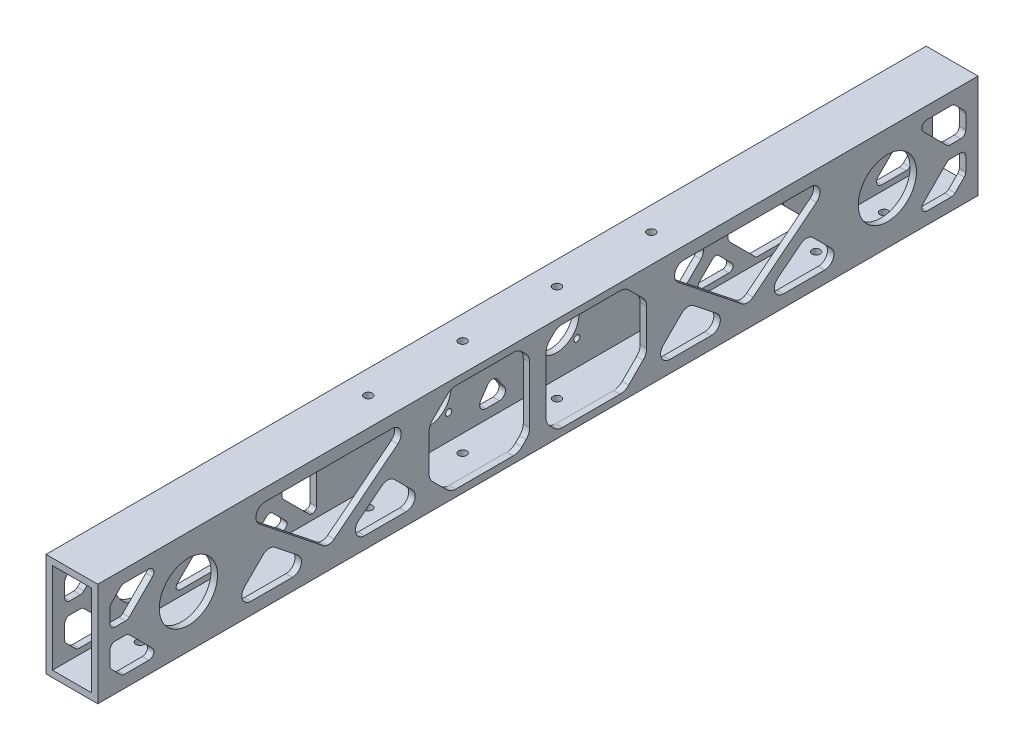
from build123d import *

# Parameters (mm, degrees)
SKETCH1_W            = 25.4
SKETCH1_H            = 50.8
SKETCH1_W_2          = 19.05
SKETCH1_H_2          = 44.45
BOSS_EXTRUDE1_DEPTH  = 431.8
SKETCH2_R            = 14.2875
CUT_EXTRUDE1_DEPTH   = 431.8
SKETCH3_R            = 1.5
SKETCH3_R_2          = 11
CUT_EXTRUDE2_DEPTH   = 3.175
SKETCH4_R            = 7
CUT_EXTRUDE3_DEPTH   = 3.175
SKETCH5_R            = 7
CUT_EXTRUDE4_DEPTH   = 3.175
CUT_EXTRUDE5_DEPTH   = 10
CUT_EXTRUDE6_DEPTH   = 10
FILLET1_R            = 4.5
FILLET4_R            = 6
FILLET1_OF_MIRROR6_R = 4.5
CUT_EXTRUDE7_DEPTH   = 26.4
FILLET5_R            = 2.5
FILLET5_OF_MIRROR7_R = 2.5
CUT_EXTRUDE8_DEPTH   = 10
FILLET6_R            = 2
FILLET7_R            = 4
FILLET6_OF_MIRROR8_R = 2
FILLET7_OF_MIRROR8_R = 4
SKETCH11_R           = 2
CUT_EXTRUDE9_DEPTH   = 51.8
CUT_EXTRUDE10_DEPTH  = 10
FILLET8_R            = 3
SKETCH15_R           = 2
CUT_EXTRUDE11_DEPTH  = 10


with BuildPart() as part:
    # Sketch1 → Boss-Extrude1 (new body)
    with BuildSketch(Plane.XY):
        with Locations((12.7, 25.4)):
            Rectangle(SKETCH1_W, SKETCH1_H)
        with Locations((12.7, 25.4)):
            Rectangle(SKETCH1_W_2, SKETCH1_H_2, mode=Mode.SUBTRACT)
    extrude(amount=BOSS_EXTRUDE1_DEPTH)

    # Sketch2 → Cut-Extrude1 (cut)
    with BuildSketch(Plane.ZY):
        with Locations((44.45, 25.4)):
            Circle(SKETCH2_R)
        with Locations((387.35, 25.4)):
            Circle(SKETCH2_R)
    extrude(amount=-CUT_EXTRUDE1_DEPTH, mode=Mode.SUBTRACT)

    # Sketch3 → Cut-Extrude2 (cut)
    with BuildSketch(Plane.ZY):
        with Locations((194.374614937, 35.299494937)):
            Circle(SKETCH3_R)
        with Locations((194.374614937, 15.500505063)):
            Circle(SKETCH3_R)
        with Locations((174.575625063, 15.500505063)):
            Circle(SKETCH3_R)
        with Locations((174.575625063, 35.299494937)):
            Circle(SKETCH3_R)
        with Locations((184.47512, 25.4)):
            Circle(SKETCH3_R_2)
        with Locations((247.32488, 25.4)):
            Circle(SKETCH3_R_2)
        with Locations((257.224374937, 35.299494937)):
            Circle(SKETCH3_R)
        with Locations((257.224374937, 15.500505063)):
            Circle(SKETCH3_R)
        with Locations((237.425385063, 15.500505063)):
            Circle(SKETCH3_R)
        with Locations((237.425385063, 35.299494937)):
            Circle(SKETCH3_R)
    extrude(amount=-CUT_EXTRUDE2_DEPTH, mode=Mode.SUBTRACT)

    # Sketch4 → Cut-Extrude3 (cut)
    with BuildSketch(Plane(origin=(25.4, 0, 0), x_dir=(0, 0, -1), z_dir=(1, 0, 0))):
        with Locations((-247.32488, 25.4)):
            Circle(SKETCH4_R)
        with Locations((-184.47512, 25.4)):
            Circle(SKETCH4_R)
    extrude(amount=-CUT_EXTRUDE3_DEPTH, mode=Mode.SUBTRACT)

    # Sketch5 → Cut-Extrude4 (cut)
    with BuildSketch(Plane(origin=(25.4, 0, 0), x_dir=(0, 0, -1), z_dir=(1, 0, 0))):
        with BuildLine():
            Line((-247.32488, 46.355), (-225.9, 46.355))
            Line((-225.9, 46.355), (-219.9, 40.355))
            Line((-219.9, 40.355), (-219.9, 10.445))
            Line((-219.9, 10.445), (-225.9, 4.445))
            Line((-225.9, 4.445), (-247.32488, 4.445))
            ThreePointArc((-247.32488, 4.445), (-268.27988, 25.4), (-247.32488, 46.355))
        make_face()
        with Locations((-247.32488, 25.4)):
            Circle(SKETCH5_R, mode=Mode.SUBTRACT)
        with BuildLine():
            ThreePointArc((-268.27988, 25.4), (-262.1423026, 40.2174226), (-247.32488, 46.355))
            Line((-247.32488, 46.355), (-258.27988, 46.355))
            Line((-258.27988, 46.355), (-268.27988, 36.355))
            Line((-268.27988, 36.355), (-268.27988, 25.4))
        make_face()
        with BuildLine():
            ThreePointArc((-247.32488, 4.445), (-262.1423026, 10.5825774), (-268.27988, 25.4))
            Line((-268.27988, 25.4), (-268.27988, 14.445))
            Line((-268.27988, 14.445), (-258.27988, 4.445))
            Line((-258.27988, 4.445), (-247.32488, 4.445))
        make_face()
        with BuildLine():
            ThreePointArc((-184.47512, 4.445), (-163.52012, 25.4), (-184.47512, 46.355))
            Line((-184.47512, 46.355), (-205.9, 46.355))
            Line((-205.9, 46.355), (-211.9, 40.355))
            Line((-211.9, 40.355), (-211.9, 10.445))
            Line((-211.9, 10.445), (-205.9, 4.445))
            Line((-205.9, 4.445), (-184.47512, 4.445))
        make_face()
        with Locations((-184.47512, 25.4)):
            Circle(SKETCH5_R, mode=Mode.SUBTRACT)
        with BuildLine():
            Line((-163.52012, 36.355), (-173.52012, 46.355))
            Line((-173.52012, 46.355), (-184.47512, 46.355))
            ThreePointArc((-184.47512, 46.355), (-169.6576974, 40.2174226), (-163.52012, 25.4))
            Line((-163.52012, 25.4), (-163.52012, 36.355))
        make_face()
        with BuildLine():
            Line((-163.52012, 14.445), (-163.52012, 25.4))
            ThreePointArc((-163.52012, 25.4), (-169.6576974, 10.5825774), (-184.47512, 4.445))
            Line((-184.47512, 4.445), (-173.52012, 4.445))
            Line((-173.52012, 4.445), (-163.52012, 14.445))
        make_face()
    extrude(amount=-CUT_EXTRUDE4_DEPTH, mode=Mode.SUBTRACT)

    # Sketch6 → Cut-Extrude5 (cut)
    with BuildSketch(Plane(origin=(25.4, 0, 0), x_dir=(0, 0, -1), z_dir=(1, 0, 0))):
        Polygon((-211.9, 10.445), (-211.9, 9.030786438), (-206.314213562, 3.445), (-173.105906438, 3.445), (-162.52012, 14.030786438), (-162.52012, 36.769213562), (-173.105906438, 47.355), (-206.314213562, 47.355), (-211.9, 41.769213562), (-211.9, 40.355), (-205.9, 46.355), (-173.52012, 46.355), (-163.52012, 36.355), (-163.52012, 14.445), (-173.52012, 4.445), (-205.9, 4.445), align=None)
        Polygon((-225.485786438, 3.445), (-219.9, 9.030786438), (-219.9, 10.445), (-225.9, 4.445), (-258.27988, 4.445), (-268.27988, 14.445), (-268.27988, 36.355), (-258.27988, 46.355), (-225.9, 46.355), (-219.9, 40.355), (-219.9, 41.769213562), (-225.485786438, 47.355), (-258.694093562, 47.355), (-269.27988, 36.769213562), (-269.27988, 14.030786438), (-258.694093562, 3.445), align=None)
    extrude(amount=-CUT_EXTRUDE5_DEPTH, mode=Mode.SUBTRACT)

    # Sketch8 → Cut-Extrude6 (cut)
    with BuildSketch(Plane(origin=(25.4, 0, 0), x_dir=(0, 0, -1), z_dir=(1, 0, 0))):
        Polygon((-289.22948352, 25.495108583), (-313.789584641, 6), (-269.734374937, 6), align=None)
        Polygon((-367.495505063, 6), (-323.440295359, 6), (-348.00039648, 25.495108583), align=None)
        Polygon((-318.61494, 9.830229616), (-274.559730296, 44.8), (-362.670149704, 44.8), align=None)
    cut_extrude6 = extrude(amount=-CUT_EXTRUDE6_DEPTH, mode=Mode.SUBTRACT)

    # Fillet1
    fillet1_edges = [part.edges().sort_by_distance(p)[0] for p in [
        (23.8125, 25.495108583, 289.22948352),
        (23.8125, 6, 269.734374937),
        (23.8125, 6, 313.789584641),
        (23.8125, 6, 367.495505063),
        (23.8125, 25.495108583, 348.00039648),
        (23.8125, 6, 323.440295359),
        (23.8125, 44.8, 274.559730296),
        (23.8125, 9.830229616, 318.61494),
        (23.8125, 44.8, 362.670149704),
    ]]
    fillet(fillet1_edges, radius=FILLET1_R)

    # Fillet4
    fillet4_edges = [part.edges().sort_by_distance(p)[0] for p in [
        (23.8125, 9.030786438, 219.9),
        (23.8125, 3.445, 225.485786438),
        (23.8125, 3.445, 258.694093562),
        (23.8125, 14.030786438, 269.27988),
        (23.8125, 36.769213562, 269.27988),
        (23.8125, 47.355, 258.694093562),
        (23.8125, 47.355, 225.485786438),
        (23.8125, 41.769213562, 219.9),
        (23.8125, 41.769213562, 211.9),
        (23.8125, 47.355, 206.314213562),
        (23.8125, 47.355, 173.105906438),
        (23.8125, 36.769213562, 162.52012),
        (23.8125, 14.030786438, 162.52012),
        (23.8125, 3.445, 173.105906438),
        (23.8125, 3.445, 206.314213562),
        (23.8125, 9.030786438, 211.9),
    ]]
    fillet(fillet4_edges, radius=FILLET4_R)

    # Mirror6: Cut-Extrude6 across plane
    add(cut_extrude6.mirror(Plane.XY.offset(215.9)), mode=Mode.SUBTRACT)

    # Fillet1 of Mirror6
    fillet1_of_mirror6_edges = [part.edges().sort_by_distance(p)[0] for p in [
        (23.8125, 25.495108583, 142.57051648),
        (23.8125, 6, 162.065625063),
        (23.8125, 6, 118.010415359),
        (23.8125, 6, 64.304494937),
        (23.8125, 25.495108583, 83.79960352),
        (23.8125, 6, 108.359704641),
        (23.8125, 44.8, 157.240269704),
        (23.8125, 9.830229616, 113.18506),
        (23.8125, 44.8, 69.129850296),
    ]]
    fillet(fillet1_of_mirror6_edges, radius=FILLET1_OF_MIRROR6_R)

    # Sketch9 → Cut-Extrude7 (cut, through all)
    with BuildSketch(Plane(origin=(25.4, 0, 0), x_dir=(0, 0, -1), z_dir=(1, 0, 0))):
        Polygon((-425.8, 38.8), (-425.8, 28.4), (-417.136846017, 28.4), (-400.736846017, 44.8), (-419.8, 44.8), align=None)
        Polygon((-417.136846017, 22.4), (-425.8, 22.4), (-425.8, 12), (-419.8, 6), (-400.736846017, 6), align=None)
    cut_extrude7 = extrude(amount=-CUT_EXTRUDE7_DEPTH, mode=Mode.SUBTRACT)

    # Fillet5
    fillet5_edges = [part.edges().sort_by_distance(p)[0] for p in [
        (23.8125, 44.8, 419.8),
        (23.8125, 44.8, 400.736846017),
        (23.8125, 28.4, 417.136846017),
        (23.8125, 28.4, 425.8),
        (23.8125, 38.8, 425.8),
        (1.5875, 44.8, 419.8),
        (1.5875, 44.8, 400.736846017),
        (1.5875, 28.4, 417.136846017),
        (1.5875, 28.4, 425.8),
        (1.5875, 38.8, 425.8),
        (23.8125, 12, 425.8),
        (23.8125, 22.4, 425.8),
        (23.8125, 22.4, 417.136846017),
        (23.8125, 6, 400.736846017),
        (23.8125, 6, 419.8),
        (1.5875, 12, 425.8),
        (1.5875, 22.4, 425.8),
        (1.5875, 22.4, 417.136846017),
        (1.5875, 6, 400.736846017),
        (1.5875, 6, 419.8),
    ]]
    fillet(fillet5_edges, radius=FILLET5_R)

    # Mirror7: Cut-Extrude7 across plane
    add(cut_extrude7.mirror(Plane.XY.offset(215.9)), mode=Mode.SUBTRACT)

    # Fillet5 of Mirror7
    fillet5_of_mirror7_edges = [part.edges().sort_by_distance(p)[0] for p in [
        (23.8125, 44.8, 12),
        (23.8125, 44.8, 31.063153983),
        (23.8125, 28.4, 14.663153983),
        (23.8125, 28.4, 6),
        (23.8125, 38.8, 6),
        (1.5875, 44.8, 12),
        (1.5875, 44.8, 31.063153983),
        (1.5875, 28.4, 14.663153983),
        (1.5875, 28.4, 6),
        (1.5875, 38.8, 6),
        (23.8125, 12, 6),
        (23.8125, 22.4, 6),
        (23.8125, 22.4, 14.663153983),
        (23.8125, 6, 31.063153983),
        (23.8125, 6, 12),
        (1.5875, 12, 6),
        (1.5875, 22.4, 6),
        (1.5875, 22.4, 14.663153983),
        (1.5875, 6, 31.063153983),
        (1.5875, 6, 12),
    ]]
    fillet(fillet5_of_mirror7_edges, radius=FILLET5_OF_MIRROR7_R)

    # Sketch10 → Cut-Extrude8 (cut)
    with BuildSketch(Plane.ZY):
        Polygon((86.57101158, 6), (57.836846017, 6), (62.10461297, 10.267766953), (73.50461297, 21.667766953), (73.50461297, 29.132233047), (62.10461297, 40.532233047), (57.836846017, 44.8), (86.57101158, 44.8), (90.838778533, 40.532233047), (100.48141922, 30.88959236), (100.48141922, 19.91040764), (90.838778533, 10.267766953), align=None)
        Polygon((95.08141922, 44.774873734), (117.906545486, 44.8), (106.48141922, 33.374873734), align=None)
        Polygon((95.08141922, 6.025126266), (106.48141922, 17.425126266), (117.906545486, 6), align=None)
        Polygon((126.39182686, 44.8), (122.124059907, 40.532233047), (112.48141922, 30.88959236), (112.48141922, 19.91040764), (122.124059907, 10.267766953), (126.39182686, 6), (129.5, 6), (129.5, 44.8), align=None)
    cut_extrude8 = extrude(amount=-CUT_EXTRUDE8_DEPTH, mode=Mode.SUBTRACT)

    # Fillet6
    fillet6_edges = [part.edges().sort_by_distance(p)[0] for p in [
        (1.5875, 44.774873734, 95.08141922),
        (1.5875, 44.8, 117.906545486),
        (1.5875, 33.374873734, 106.48141922),
        (1.5875, 6.025126266, 95.08141922),
        (1.5875, 17.425126266, 106.48141922),
        (1.5875, 6, 117.906545486),
        (1.5875, 44.8, 126.39182686),
        (1.5875, 44.8, 129.5),
        (1.5875, 6, 129.5),
        (1.5875, 6, 126.39182686),
        (1.5875, 6, 57.836846017),
        (1.5875, 44.8, 57.836846017),
    ]]
    fillet(fillet6_edges, radius=FILLET6_R)

    # Fillet7
    fillet7_edges = [part.edges().sort_by_distance(p)[0] for p in [
        (1.5875, 30.88959236, 112.48141922),
        (1.5875, 19.91040764, 112.48141922),
        (1.5875, 21.667766953, 73.50461297),
        (1.5875, 29.132233047, 73.50461297),
        (1.5875, 30.88959236, 100.48141922),
        (1.5875, 19.91040764, 100.48141922),
    ]]
    fillet(fillet7_edges, radius=FILLET7_R)

    # Mirror8: Cut-Extrude8 across plane
    add(cut_extrude8.mirror(Plane.XY.offset(215.9)), mode=Mode.SUBTRACT)

    # Fillet6 of Mirror8
    fillet6_of_mirror8_edges = [part.edges().sort_by_distance(p)[0] for p in [
        (1.5875, 44.774873734, 336.71858078),
        (1.5875, 44.8, 313.893454514),
        (1.5875, 33.374873734, 325.31858078),
        (1.5875, 6.025126266, 336.71858078),
        (1.5875, 17.425126266, 325.31858078),
        (1.5875, 6, 313.893454514),
        (1.5875, 44.8, 305.40817314),
        (1.5875, 44.8, 302.3),
        (1.5875, 6, 302.3),
        (1.5875, 6, 305.40817314),
        (1.5875, 6, 373.963153983),
        (1.5875, 44.8, 373.963153983),
    ]]
    fillet(fillet6_of_mirror8_edges, radius=FILLET6_OF_MIRROR8_R)

    # Fillet7 of Mirror8
    fillet7_of_mirror8_edges = [part.edges().sort_by_distance(p)[0] for p in [
        (1.5875, 30.88959236, 319.31858078),
        (1.5875, 19.91040764, 319.31858078),
        (1.5875, 21.667766953, 358.29538703),
        (1.5875, 29.132233047, 358.29538703),
        (1.5875, 30.88959236, 331.31858078),
        (1.5875, 19.91040764, 331.31858078),
    ]]
    fillet(fillet7_of_mirror8_edges, radius=FILLET7_OF_MIRROR8_R)

    # Sketch11 → Cut-Extrude9 (cut, through all)
    with BuildSketch(Plane.XZ):
        with Locations((11.556542301, 285.272895731)):
            Circle(SKETCH11_R)
        with Locations((11.555932218, 238.983920373)):
            Circle(SKETCH11_R)
        with Locations((11.555322134, 192.694945016)):
            Circle(SKETCH11_R)
        with Locations((11.55471205, 146.405969658)):
            Circle(SKETCH11_R)
    extrude(amount=-CUT_EXTRUDE9_DEPTH, mode=Mode.SUBTRACT)

    # Sketch14 → Cut-Extrude10 (cut)
    with BuildSketch(Plane.ZY):
        Polygon((215.9, 29.571243445), (224.9, 42.8), (206.9, 42.8), align=None)
        Polygon((215.9, 21.228756555), (224.9, 8), (206.9, 8), align=None)
    extrude(amount=-CUT_EXTRUDE10_DEPTH, mode=Mode.SUBTRACT)

    # Fillet8
    fillet8_edges = [part.edges().sort_by_distance(p)[0] for p in [
        (1.5875, 42.8, 206.9),
        (1.5875, 42.8, 224.9),
        (1.5875, 29.571243445, 215.9),
        (1.5875, 21.228756555, 215.9),
        (1.5875, 8, 224.9),
        (1.5875, 8, 206.9),
    ]]
    fillet(fillet8_edges, radius=FILLET8_R)

    # Sketch15 → Cut-Extrude11 (cut)
    with BuildSketch(Plane.XZ.offset(1.5875)):
        with Locations((12.7, 365.055337133)):
            Circle(SKETCH15_R)
        with Locations((12.7, 66.744662867)):
            Circle(SKETCH15_R)
        with Locations((12.7, 33.372331434)):
            Circle(SKETCH15_R)
        with Locations((12.7, 398.427668566)):
            Circle(SKETCH15_R)
    extrude(amount=-CUT_EXTRUDE11_DEPTH, mode=Mode.SUBTRACT)


solid = part.part
